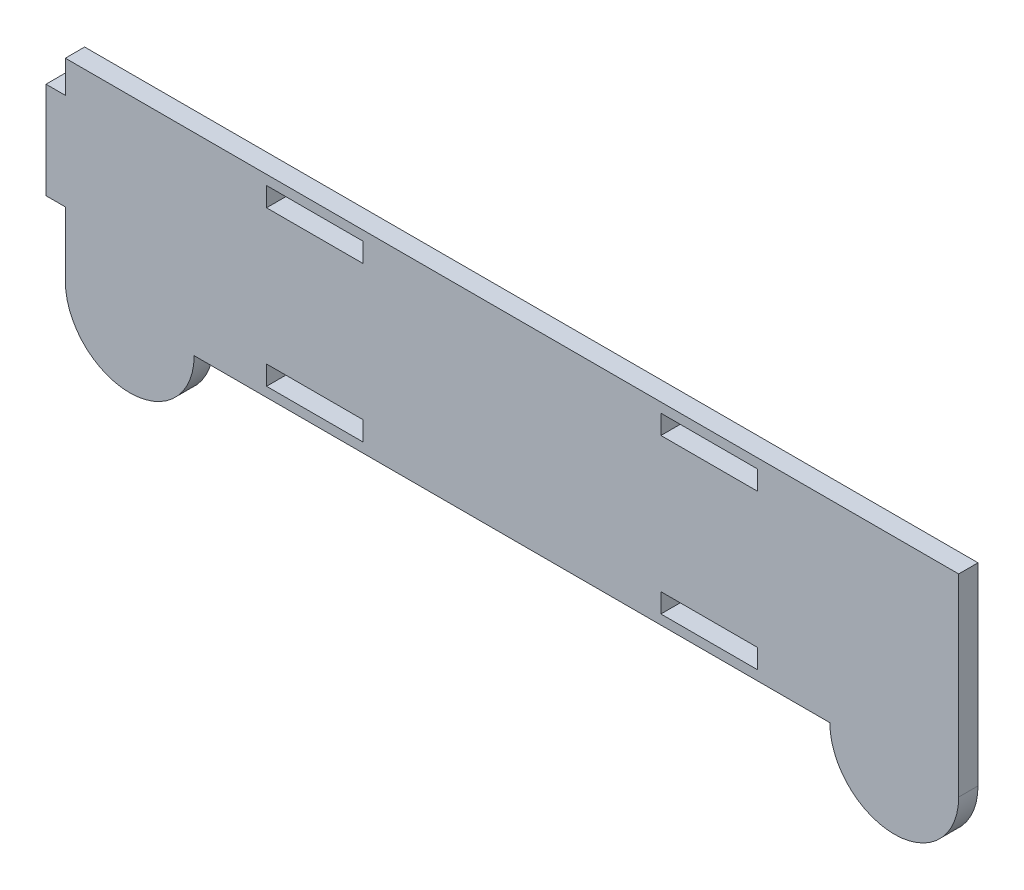
from build123d import *

# Parameters (mm, degrees)
BOSS_EXTRUDE1_DEPTH = 3
SKETCH2_W           = 15
SKETCH2_H           = 3
CUT_EXTRUDE1_DEPTH  = 4


with BuildPart() as part:
    # Sketch1 → Boss-Extrude1 (new body)
    with BuildSketch(Plane.XY):
        with BuildLine():
            Line((138.7, 8.95909513), (138.7, 38.95909513))
            Line((138.7, 38.95909513), (0, 38.95909513))
            Line((0, 38.95909513), (0, 33.95909513))
            Line((0, 33.95909513), (-3, 33.95909513))
            Line((-3, 33.95909513), (-3, 18.95909513))
            Line((-3, 18.95909513), (0, 18.95909513))
            Line((0, 18.95909513), (0, 8.95909513))
            ThreePointArc((0, 8.95909513), (10, -1.04090487), (20, 8.95909513))
            Line((20, 8.95909513), (118.7, 8.95909513))
            ThreePointArc((118.7, 8.95909513), (128.7, -1.04090487), (138.7, 8.95909513))
        make_face()
    extrude(amount=BOSS_EXTRUDE1_DEPTH)

    # Sketch2 → Cut-Extrude1 (cut, through all)
    with BuildSketch(Plane.XY.offset(3)):
        with Locations((38.74, 35.95909513)):
            Rectangle(SKETCH2_W, SKETCH2_H)
        with Locations((99.97, 35.95909513)):
            Rectangle(SKETCH2_W, SKETCH2_H)
        with Locations((38.74, 11.95909513)):
            Rectangle(SKETCH2_W, SKETCH2_H)
        with Locations((99.97, 11.95909513)):
            Rectangle(SKETCH2_W, SKETCH2_H)
    extrude(amount=-CUT_EXTRUDE1_DEPTH, mode=Mode.SUBTRACT)


solid = part.part
